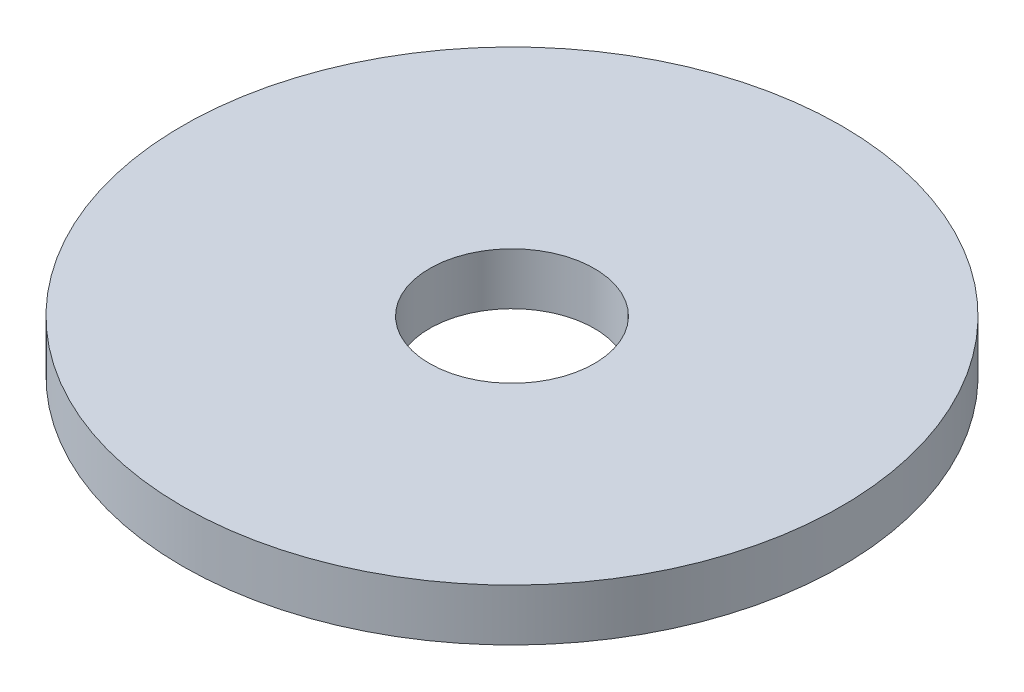
from build123d import *

# Parameters (mm, degrees)
SKETCH1_W = 7.14375
SKETCH1_H = 1.5


with BuildPart() as part:
    # Sketch1 → Revolve1 (revolve)
    with BuildSketch(Plane.XY):
        with Locations((-5.953125, -0.75)):
            Rectangle(SKETCH1_W, SKETCH1_H)
    revolve(axis=Axis((0, 299.544827586, 0), (0, -1, 0)))


solid = part.part
